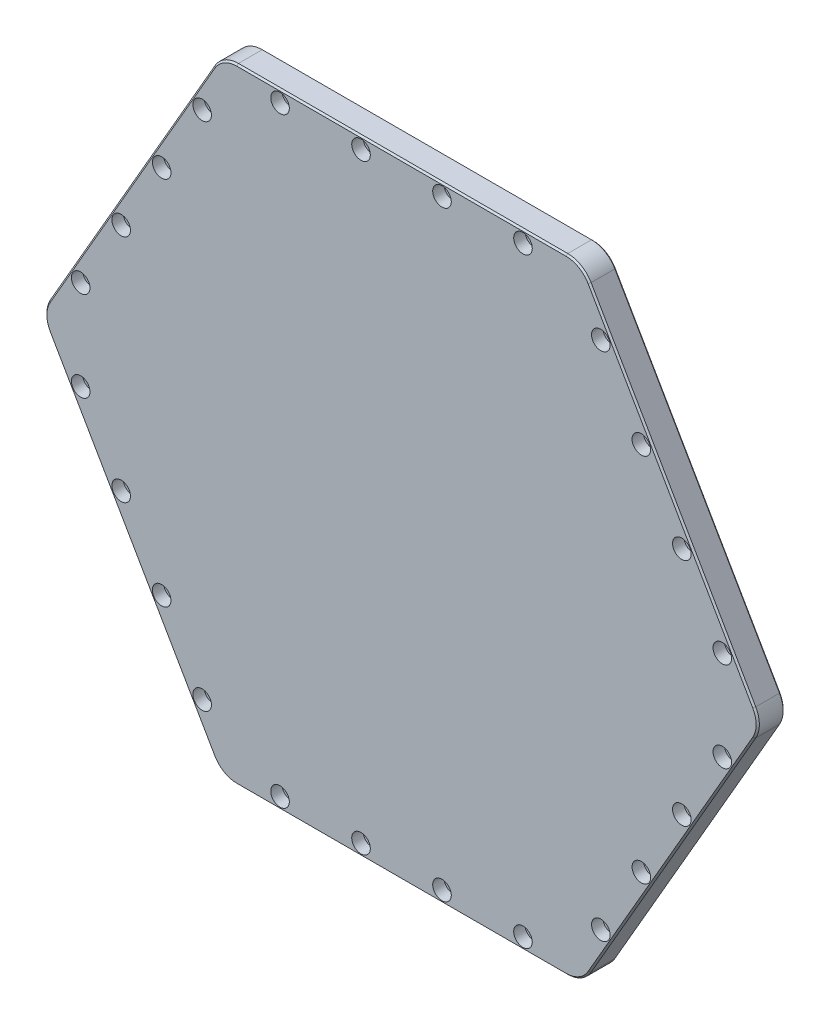
from build123d import *

# Parameters (mm, degrees)
EXTRUDE1_DEPTH                                = 25.4
FILLET1_R                                     = 25.4
CHAMFER1_SIZE                                 = 1.524
CBORE_FOR_3_8_SOCKET_HEAD_CAP_SCREW1_AT_COUNT = 2
CBORE_FOR_3_8_SOCKET_HEAD_CAP_SCREW1_AT_PITCH = 76.2
CBORE_FOR_3_8_SOCKET_HEAD_CAP_SCREW1_2_COUNT  = 2
CBORE_FOR_3_8_SOCKET_HEAD_CAP_SCREW1_2_PITCH  = 76.2
CBORE_FOR_3_8_SOCKET_HEAD_CAP_SCREW1_3_COUNT  = 2
CBORE_FOR_3_8_SOCKET_HEAD_CAP_SCREW1_3_PITCH  = 152.4
CIRPATTERN1_COUNT                             = 6


with BuildPart() as part:
    # Sketch1 → Extrude1 (new body)
    with BuildSketch(Plane.XY):
        Polygon((169.560557183, 293.6875), (-169.560557183, 293.6875), (-339.121114365, 0), (-169.560557183, -293.6875), (169.560557183, -293.6875), (339.121114365, 0), align=None)
    extrude(amount=EXTRUDE1_DEPTH)

    # Fillet1
    fillet1_edges = [part.edges().sort_by_distance(p)[0] for p in [
        (-169.560557183, -293.6875, 12.7),
        (-339.121114365, 0, 12.7),
        (-169.560557183, 293.6875, 12.7),
        (169.560557183, 293.6875, 12.7),
        (339.121114365, 0, 12.7),
        (169.560557183, -293.6875, 12.7),
    ]]
    fillet(fillet1_edges, radius=FILLET1_R)

    # Chamfer1
    chamfer1_edges = [part.edges().sort_by_distance(p)[0] for p in [
        (-254.340835774, -146.84375, 0),
        (-254.340835774, -146.84375, 25.4),
        (254.340835774, 146.84375, 0),
        (254.340835774, -146.84375, 0),
        (0, -293.6875, 0),
        (-254.340835774, 146.84375, 0),
        (0, 293.6875, 0),
        (167.595860345, 290.284545256, 0),
        (-167.595860345, 290.284545256, 0),
        (335.19172069, 0, 0),
        (167.595860345, -290.284545256, 0),
        (-167.595860345, -290.284545256, 0),
        (-335.19172069, 0, 0),
        (-254.340835774, 146.84375, 25.4),
        (254.340835774, 146.84375, 25.4),
        (0, 293.6875, 25.4),
        (0, -293.6875, 25.4),
        (254.340835774, -146.84375, 25.4),
        (167.595860345, 290.284545256, 25.4),
        (-167.595860345, 290.284545256, 25.4),
        (335.19172069, 0, 25.4),
        (167.595860345, -290.284545256, 25.4),
        (-167.595860345, -290.284545256, 25.4),
        (-335.19172069, 0, 25.4),
    ]]
    chamfer(chamfer1_edges, length=CHAMFER1_SIZE)

    # Sketch2 → CBORE for 3_8 Socket Head Cap Screw1 (revolve, cut)
    with BuildSketch(Plane(origin=(-38.1, -282.575, 25.4), x_dir=(0, -1, 0), z_dir=(1, 0, 0))):
        Polygon((0, 0), (0, 25.4), (5.842, 25.4), (5.15874, 24.613999282), (5.15874, 10.668), (8.7376, 10.668), (8.7376, 0), align=None)
    cbore_for_3_8_socket_head_cap_screw1 = revolve(axis=Axis((-38.1, -282.575, 31.75), (0, 0, -1)), mode=Mode.SUBTRACT)

    # CBORE for 3_8 Socket Head Cap Screw1 at: CBORE for 3_8 Socket Head Cap Screw1 ×2
    with Locations(*[(-i * CBORE_FOR_3_8_SOCKET_HEAD_CAP_SCREW1_AT_PITCH, 0, 0) for i in range(1, CBORE_FOR_3_8_SOCKET_HEAD_CAP_SCREW1_AT_COUNT)]):
        add(cbore_for_3_8_socket_head_cap_screw1, mode=Mode.SUBTRACT)

    # CBORE for 3_8 Socket Head Cap Screw1 2: CBORE for 3_8 Socket Head Cap Screw1 ×2
    with Locations(*[(i * CBORE_FOR_3_8_SOCKET_HEAD_CAP_SCREW1_2_PITCH, 0, 0) for i in range(1, CBORE_FOR_3_8_SOCKET_HEAD_CAP_SCREW1_2_COUNT)]):
        add(cbore_for_3_8_socket_head_cap_screw1, mode=Mode.SUBTRACT)

    # CBORE for 3_8 Socket Head Cap Screw1 3: CBORE for 3_8 Socket Head Cap Screw1 ×2
    with Locations(*[(i * CBORE_FOR_3_8_SOCKET_HEAD_CAP_SCREW1_3_PITCH, 0, 0) for i in range(1, CBORE_FOR_3_8_SOCKET_HEAD_CAP_SCREW1_3_COUNT)]):
        add(cbore_for_3_8_socket_head_cap_screw1, mode=Mode.SUBTRACT)

    # CirPattern1: CBORE for 3_8 Socket Head Cap Screw1 ×6 about axis
    cirpattern1_axis = Axis((0, 0, 0), (0, 0, 1))
    for i in range(1, CIRPATTERN1_COUNT):
        add(cbore_for_3_8_socket_head_cap_screw1.rotate(cirpattern1_axis, i * 360 / CIRPATTERN1_COUNT), mode=Mode.SUBTRACT)

    # CirPattern1 copy 1 sketch → CirPattern1 copy 1 (revolve, cut)
    with BuildSketch(Plane(origin=(187.567128474, -240.274203653, 25.4), x_dir=(0.866025404, -0.5, 0), z_dir=(0.5, 0.866025404, 0))):
        Polygon((0, 0), (0, 25.4), (5.842, 25.4), (5.15874, 24.613999282), (5.15874, 10.668), (8.7376, 10.668), (8.7376, 0), align=None)
    revolve(axis=Axis((187.567128474, -240.274203653, 31.75), (0, 0, -1)), mode=Mode.SUBTRACT)

    # CirPattern1 copy 2 sketch → CirPattern1 copy 2 (revolve, cut)
    with BuildSketch(Plane(origin=(301.867128474, 42.300796347, 25.4), x_dir=(0.866025404, 0.5, 0), z_dir=(-0.5, 0.866025404, 0))):
        Polygon((0, 0), (0, 25.4), (5.842, 25.4), (5.15874, 24.613999282), (5.15874, 10.668), (8.7376, 10.668), (8.7376, 0), align=None)
    revolve(axis=Axis((301.867128474, 42.300796347, 31.75), (0, 0, -1)), mode=Mode.SUBTRACT)

    # CirPattern1 copy 3 sketch → CirPattern1 copy 3 (revolve, cut)
    with BuildSketch(Plane(origin=(114.3, 282.575, 25.4), x_dir=(0, 1, 0), z_dir=(-1, 0, 0))):
        Polygon((0, 0), (0, 25.4), (5.842, 25.4), (5.15874, 24.613999282), (5.15874, 10.668), (8.7376, 10.668), (8.7376, 0), align=None)
    revolve(axis=Axis((114.3, 282.575, 31.75), (0, 0, -1)), mode=Mode.SUBTRACT)

    # CirPattern1 copy 4 sketch → CirPattern1 copy 4 (revolve, cut)
    with BuildSketch(Plane(origin=(-187.567128474, 240.274203653, 25.4), x_dir=(-0.866025404, 0.5, 0), z_dir=(-0.5, -0.866025404, 0))):
        Polygon((0, 0), (0, 25.4), (5.842, 25.4), (5.15874, 24.613999282), (5.15874, 10.668), (8.7376, 10.668), (8.7376, 0), align=None)
    revolve(axis=Axis((-187.567128474, 240.274203653, 31.75), (0, 0, -1)), mode=Mode.SUBTRACT)

    # CirPattern1 copy 5 sketch → CirPattern1 copy 5 (revolve, cut)
    with BuildSketch(Plane(origin=(-301.867128474, -42.300796347, 25.4), x_dir=(-0.866025404, -0.5, 0), z_dir=(0.5, -0.866025404, 0))):
        Polygon((0, 0), (0, 25.4), (5.842, 25.4), (5.15874, 24.613999282), (5.15874, 10.668), (8.7376, 10.668), (8.7376, 0), align=None)
    revolve(axis=Axis((-301.867128474, -42.300796347, 31.75), (0, 0, -1)), mode=Mode.SUBTRACT)

    # CirPattern1 copy 6 sketch → CirPattern1 copy 6 (revolve, cut)
    with BuildSketch(Plane(origin=(263.767128474, -108.291932116, 25.4), x_dir=(0.866025404, -0.5, 0), z_dir=(0.5, 0.866025404, 0))):
        Polygon((0, 0), (0, 25.4), (5.842, 25.4), (5.15874, 24.613999282), (5.15874, 10.668), (8.7376, 10.668), (8.7376, 0), align=None)
    revolve(axis=Axis((263.767128474, -108.291932116, 31.75), (0, 0, -1)), mode=Mode.SUBTRACT)

    # CirPattern1 copy 7 sketch → CirPattern1 copy 7 (revolve, cut)
    with BuildSketch(Plane(origin=(225.667128474, 174.283067884, 25.4), x_dir=(0.866025404, 0.5, 0), z_dir=(-0.5, 0.866025404, 0))):
        Polygon((0, 0), (0, 25.4), (5.842, 25.4), (5.15874, 24.613999282), (5.15874, 10.668), (8.7376, 10.668), (8.7376, 0), align=None)
    revolve(axis=Axis((225.667128474, 174.283067884, 31.75), (0, 0, -1)), mode=Mode.SUBTRACT)

    # CirPattern1 copy 8 sketch → CirPattern1 copy 8 (revolve, cut)
    with BuildSketch(Plane(origin=(-38.1, 282.575, 25.4), x_dir=(0, 1, 0), z_dir=(-1, 0, 0))):
        Polygon((0, 0), (0, 25.4), (5.842, 25.4), (5.15874, 24.613999282), (5.15874, 10.668), (8.7376, 10.668), (8.7376, 0), align=None)
    revolve(axis=Axis((-38.1, 282.575, 31.75), (0, 0, -1)), mode=Mode.SUBTRACT)

    # CirPattern1 copy 9 sketch → CirPattern1 copy 9 (revolve, cut)
    with BuildSketch(Plane(origin=(-263.767128474, 108.291932116, 25.4), x_dir=(-0.866025404, 0.5, 0), z_dir=(-0.5, -0.866025404, 0))):
        Polygon((0, 0), (0, 25.4), (5.842, 25.4), (5.15874, 24.613999282), (5.15874, 10.668), (8.7376, 10.668), (8.7376, 0), align=None)
    revolve(axis=Axis((-263.767128474, 108.291932116, 31.75), (0, 0, -1)), mode=Mode.SUBTRACT)

    # CirPattern1 copy 10 sketch → CirPattern1 copy 10 (revolve, cut)
    with BuildSketch(Plane(origin=(-225.667128474, -174.283067884, 25.4), x_dir=(-0.866025404, -0.5, 0), z_dir=(0.5, -0.866025404, 0))):
        Polygon((0, 0), (0, 25.4), (5.842, 25.4), (5.15874, 24.613999282), (5.15874, 10.668), (8.7376, 10.668), (8.7376, 0), align=None)
    revolve(axis=Axis((-225.667128474, -174.283067884, 31.75), (0, 0, -1)), mode=Mode.SUBTRACT)

    # CirPattern1 copy 11 sketch → CirPattern1 copy 11 (revolve, cut)
    with BuildSketch(Plane(origin=(301.867128474, -42.300796347, 25.4), x_dir=(0.866025404, -0.5, 0), z_dir=(0.5, 0.866025404, 0))):
        Polygon((0, 0), (0, 25.4), (5.842, 25.4), (5.15874, 24.613999282), (5.15874, 10.668), (8.7376, 10.668), (8.7376, 0), align=None)
    revolve(axis=Axis((301.867128474, -42.300796347, 31.75), (0, 0, -1)), mode=Mode.SUBTRACT)

    # CirPattern1 copy 12 sketch → CirPattern1 copy 12 (revolve, cut)
    with BuildSketch(Plane(origin=(187.567128474, 240.274203653, 25.4), x_dir=(0.866025404, 0.5, 0), z_dir=(-0.5, 0.866025404, 0))):
        Polygon((0, 0), (0, 25.4), (5.842, 25.4), (5.15874, 24.613999282), (5.15874, 10.668), (8.7376, 10.668), (8.7376, 0), align=None)
    revolve(axis=Axis((187.567128474, 240.274203653, 31.75), (0, 0, -1)), mode=Mode.SUBTRACT)

    # CirPattern1 copy 13 sketch → CirPattern1 copy 13 (revolve, cut)
    with BuildSketch(Plane(origin=(-114.3, 282.575, 25.4), x_dir=(0, 1, 0), z_dir=(-1, 0, 0))):
        Polygon((0, 0), (0, 25.4), (5.842, 25.4), (5.15874, 24.613999282), (5.15874, 10.668), (8.7376, 10.668), (8.7376, 0), align=None)
    revolve(axis=Axis((-114.3, 282.575, 31.75), (0, 0, -1)), mode=Mode.SUBTRACT)

    # CirPattern1 copy 14 sketch → CirPattern1 copy 14 (revolve, cut)
    with BuildSketch(Plane(origin=(-301.867128474, 42.300796347, 25.4), x_dir=(-0.866025404, 0.5, 0), z_dir=(-0.5, -0.866025404, 0))):
        Polygon((0, 0), (0, 25.4), (5.842, 25.4), (5.15874, 24.613999282), (5.15874, 10.668), (8.7376, 10.668), (8.7376, 0), align=None)
    revolve(axis=Axis((-301.867128474, 42.300796347, 31.75), (0, 0, -1)), mode=Mode.SUBTRACT)

    # CirPattern1 copy 15 sketch → CirPattern1 copy 15 (revolve, cut)
    with BuildSketch(Plane(origin=(-187.567128474, -240.274203653, 25.4), x_dir=(-0.866025404, -0.5, 0), z_dir=(0.5, -0.866025404, 0))):
        Polygon((0, 0), (0, 25.4), (5.842, 25.4), (5.15874, 24.613999282), (5.15874, 10.668), (8.7376, 10.668), (8.7376, 0), align=None)
    revolve(axis=Axis((-187.567128474, -240.274203653, 31.75), (0, 0, -1)), mode=Mode.SUBTRACT)


solid = part.part
